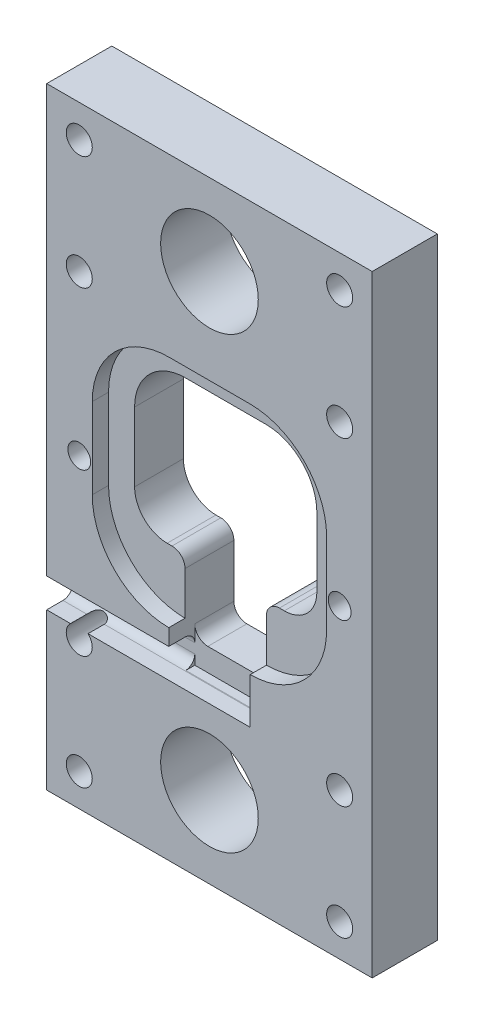
from build123d import *

# Parameters (mm, degrees)
BOSS_EXTRUDE1_DEPTH = 10
CUT_EXTRUDE1_DEPTH  = 11
SKETCH3_W           = 50
SKETCH3_H           = 45
BOSS_EXTRUDE3_DEPTH = 10
CUT_EXTRUDE6_DEPTH  = 2.5
SKETCH5_W           = 12.5
SKETCH5_H           = 6.253832763
CUT_EXTRUDE7_DEPTH  = 4
SKETCH6_W           = 50
SKETCH6_H           = 23.984880812
SKETCH6_R           = 7.5
SKETCH6_H_2         = 25
BOSS_EXTRUDE4_DEPTH = 10
CUT_EXTRUDE8_DEPTH  = 31.25
SKETCH8_R           = 2
SKETCH8_R_2         = 1.75
CUT_EXTRUDE11_DEPTH = 11
SKETCH9_R           = 2
CUT_EXTRUDE12_DEPTH = 11


with BuildPart() as part:
    # Sketch1 → Boss-Extrude1 (new body)
    with BuildSketch(Plane.XY):
        with BuildLine():
            Line((-7, 19), (7, 19))
            ThreePointArc((7, 19), (14.071067812, 16.071067812), (17, 9))
            Line((17, 9), (17, -5))
            ThreePointArc((17, -5), (14.071067812, -12.071067812), (7, -15))
            Line((7, -15), (-7, -15))
            ThreePointArc((-7, -15), (-14.071067812, -12.071067812), (-17, -5))
            Line((-17, -5), (-17, 9))
            ThreePointArc((-17, 9), (-14.071067812, 16.071067812), (-7, 19))
        make_face()
    extrude(amount=BOSS_EXTRUDE1_DEPTH)

    # Sketch2 → Cut-Extrude1 (cut, through all)
    with BuildSketch(Plane(origin=(0, 0, 0), x_dir=(-1, 0, 0), z_dir=(0, 0, -1))):
        with BuildLine():
            Line((14, 0.39), (14, 8.212908396))
            ThreePointArc((14, 8.212908396), (11.719213675, 13.719213675), (6.212908396, 16))
            Line((6.212908396, 16), (-6.212908396, 16))
            ThreePointArc((-6.212908396, 16), (-11.719213675, 13.719213675), (-14, 8.212908396))
            Line((-14, 8.212908396), (-14, 0.39))
            Line((-14, 0.39), (-14, -2.4))
            ThreePointArc((-14, -2.4), (-12.535533906, -5.935533906), (-9, -7.4))
            Line((-9, -7.4), (-8.25, -7.4))
            ThreePointArc((-8.25, -7.4), (-6.835786438, -7.985786438), (-6.25, -9.4))
            Line((-6.25, -9.4), (-6.25, -17.62539529))
            Line((-6.25, -17.62539529), (6.25, -17.62539529))
            Line((6.25, -17.62539529), (6.25, -9.4))
            ThreePointArc((6.25, -9.4), (6.835786438, -7.985786438), (8.25, -7.4))
            Line((8.25, -7.4), (9, -7.4))
            ThreePointArc((9, -7.4), (12.535533906, -5.935533906), (14, -2.4))
            Line((14, -2.4), (14, 0.39))
        make_face()
    extrude(amount=-CUT_EXTRUDE1_DEPTH, mode=Mode.SUBTRACT)

    # Sketch3 → Boss-Extrude3 (add)
    with BuildSketch(Plane(origin=(0, 0, 0), x_dir=(-1, 0, 0), z_dir=(0, 0, -1))):
        with Locations((0, -0.507559594)):
            Rectangle(SKETCH3_W, SKETCH3_H)
        with BuildLine():
            Line((-6.25, -9.4), (-6.25, -15))
            Line((-6.25, -15), (-6.25, -17.5))
            ThreePointArc((-6.25, -17.5), (-5.664213562, -18.914213562), (-4.25, -19.5))
            Line((-4.25, -19.5), (4.25, -19.5))
            ThreePointArc((4.25, -19.5), (5.664213562, -18.914213562), (6.25, -17.5))
            Line((6.25, -17.5), (6.25, -15))
            Line((6.25, -15), (6.25, -9.4))
            ThreePointArc((6.25, -9.4), (6.835786438, -7.985786438), (8.25, -7.4))
            Line((8.25, -7.4), (9, -7.4))
            ThreePointArc((9, -7.4), (12.535533906, -5.935533906), (14, -2.4))
            Line((14, -2.4), (14, 8.212908396))
            ThreePointArc((14, 8.212908396), (11.719213675, 13.719213675), (6.212908396, 16))
            Line((6.212908396, 16), (-6.212908396, 16))
            ThreePointArc((-6.212908396, 16), (-11.719213675, 13.719213675), (-14, 8.212908396))
            Line((-14, 8.212908396), (-14, -2.4))
            ThreePointArc((-14, -2.4), (-12.535533906, -5.935533906), (-9, -7.4))
            Line((-9, -7.4), (-8.25, -7.4))
            ThreePointArc((-8.25, -7.4), (-6.835786438, -7.985786438), (-6.25, -9.4))
        make_face(mode=Mode.SUBTRACT)
    extrude(amount=-BOSS_EXTRUDE3_DEPTH)

    # Sketch4 → Cut-Extrude6 (cut)
    with BuildSketch(Plane.XY.offset(10)):
        with BuildLine():
            Line((-18, 8.192440406), (-18, -4.207559594))
            ThreePointArc((-18, -4.207559594), (-14.543860018, -12.551419612), (-6.2, -16.007559594))
            Line((-6.2, -16.007559594), (6.2, -16.007559594))
            ThreePointArc((6.2, -16.007559594), (14.543860018, -12.551419612), (18, -4.207559594))
            Line((18, -4.207559594), (18, 8.192440406))
            ThreePointArc((18, 8.192440406), (14.543860018, 16.536300424), (6.2, 19.992440406))
            Line((6.2, 19.992440406), (-6.2, 19.992440406))
            ThreePointArc((-6.2, 19.992440406), (-14.543860018, 16.536300424), (-18, 8.192440406))
        make_face()
    extrude(amount=-CUT_EXTRUDE6_DEPTH, mode=Mode.SUBTRACT)

    # Sketch5 → Cut-Extrude7 (cut)
    with BuildSketch(Plane.XY.offset(10)):
        with Locations((0, -19.880643213)):
            Rectangle(SKETCH5_W, SKETCH5_H)
    extrude(amount=-CUT_EXTRUDE7_DEPTH, mode=Mode.SUBTRACT)

    # Sketch6 → Boss-Extrude4 (add)
    with BuildSketch(Plane(origin=(0, 0, 0), x_dir=(-1, 0, 0), z_dir=(0, 0, -1))):
        with Locations((0, -35)):
            Rectangle(SKETCH6_W, SKETCH6_H)
        with Locations((0, -34.492440406)):
            Circle(SKETCH6_R, mode=Mode.SUBTRACT)
        with Locations((0, 34.492440406)):
            Rectangle(SKETCH6_W, SKETCH6_H_2)
        with Locations((0, 34.492440406)):
            Circle(SKETCH6_R, mode=Mode.SUBTRACT)
    extrude(amount=-BOSS_EXTRUDE4_DEPTH)

    # Sketch7 → Cut-Extrude8 (cut)
    with BuildSketch(Plane.ZY.offset(25)):
        with BuildLine():
            Line((10, -18.512440406), (7.5, -18.512440406))
            ThreePointArc((7.5, -18.512440406), (6.439339828, -18.951780234), (6, -20.012440406))
            Line((6, -20.012440406), (6, -21.512440406))
            ThreePointArc((6, -21.512440406), (6.439339828, -22.573100578), (7.5, -23.012440406))
            Line((7.5, -23.012440406), (10, -23.012440406))
            Line((10, -23.012440406), (10, -18.512440406))
        make_face()
    extrude(amount=-CUT_EXTRUDE8_DEPTH, mode=Mode.SUBTRACT)

    # Sketch8 → Cut-Extrude11 (cut, through all)
    with BuildSketch(Plane.XY.offset(10)):
        with Locations((-20, 41.992440406)):
            Circle(SKETCH8_R)
        with Locations((20, 41.992440406)):
            Circle(SKETCH8_R)
        with Locations((-20, 0)):
            Circle(SKETCH8_R_2)
        with Locations((20, 0)):
            Circle(SKETCH8_R_2)
        with Locations((20, -41.992440406)):
            Circle(SKETCH8_R)
        with Locations((-20, -41.992440406)):
            Circle(SKETCH8_R)
    extrude(amount=-CUT_EXTRUDE11_DEPTH, mode=Mode.SUBTRACT)

    # Sketch9 → Cut-Extrude12 (cut, through all)
    with BuildSketch(Plane.XY.offset(10)):
        with Locations((-20, 24.492440406)):
            Circle(SKETCH9_R)
        with Locations((20, 24.492440406)):
            Circle(SKETCH9_R)
        with Locations((20, -24.492440406)):
            Circle(SKETCH9_R)
        with Locations((-20, -24.492440406)):
            Circle(SKETCH9_R)
    extrude(amount=-CUT_EXTRUDE12_DEPTH, mode=Mode.SUBTRACT)


solid = part.part
